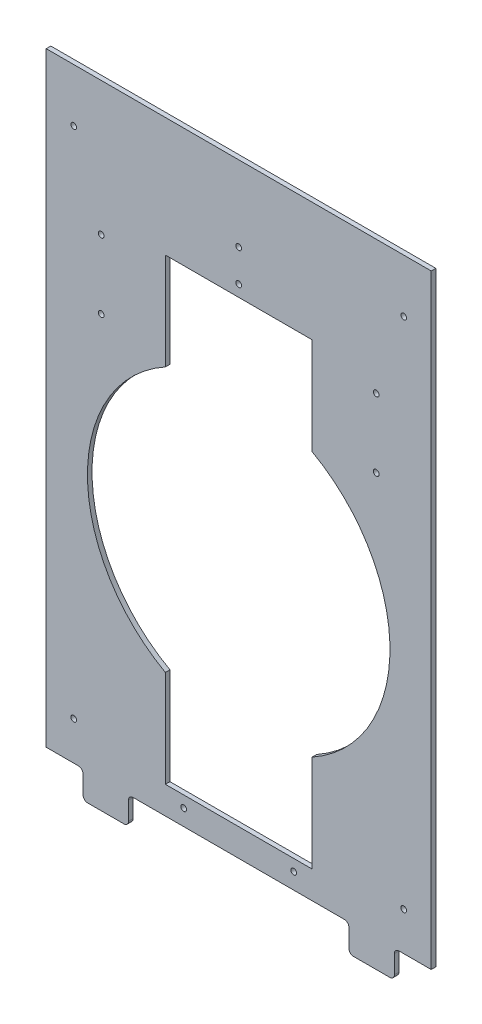
from build123d import *

# Parameters (mm, degrees)
SKETCH1_W                      = 533.4
SKETCH1_H                      = 2413
BOSS_EXTRUDE1_DEPTH            = 6.35
F_5_16_0_3125_DIAMETER_HOLE1_D = 7.9375
SKETCH6_W                      = 533.4
SKETCH6_H                      = 1546.86
CUT_EXTRUDE1_DEPTH             = 7.35
SKETCH7_W                      = 62.992
SKETCH7_H                      = 38.1
BOSS_EXTRUDE2_DEPTH            = 6.35
FILLET1_R                      = 6.35
SKETCH9_W                      = 533.4
SKETCH9_H                      = 27.94
CUT_EXTRUDE3_DEPTH             = 7.35
F_5_16_0_3125_DIAMETER_HOLE2_D = 7.9375


with BuildPart() as part:
    # Sketch1 → Boss-Extrude1 (new body)
    with BuildSketch(Plane.XY):
        with Locations((0, 1206.5)):
            Rectangle(SKETCH1_W, SKETCH1_H)
        with BuildLine():
            Line((-101.6, 797.56), (101.6, 797.56))
            Line((101.6, 797.56), (101.6, 663.332045059))
            ThreePointArc((101.6, 663.332045059), (209.55, 480.06), (101.6, 296.787954941))
            Line((101.6, 296.787954941), (101.6, 162.56))
            Line((101.6, 162.56), (-101.6, 162.56))
            Line((-101.6, 162.56), (-101.6, 296.787954941))
            ThreePointArc((-101.6, 296.787954941), (-209.55, 480.06), (-101.6, 663.332045059))
            Line((-101.6, 663.332045059), (-101.6, 797.56))
        make_face(mode=Mode.SUBTRACT)
        with BuildLine():
            Line((-101.6, 1508.76), (-101.6, 1374.532045059))
            ThreePointArc((-101.6, 1374.532045059), (-209.55, 1191.26), (-101.6, 1007.987954941))
            Line((-101.6, 1007.987954941), (-101.6, 873.76))
            Line((-101.6, 873.76), (101.6, 873.76))
            Line((101.6, 873.76), (101.6, 1007.987954941))
            ThreePointArc((101.6, 1007.987954941), (209.55, 1191.26), (101.6, 1374.532045059))
            Line((101.6, 1374.532045059), (101.6, 1508.76))
            Line((101.6, 1508.76), (-101.6, 1508.76))
        make_face(mode=Mode.SUBTRACT)
        with BuildLine():
            Line((-101.6, 2219.96), (-101.6, 2085.732045059))
            ThreePointArc((-101.6, 2085.732045059), (-209.55, 1902.46), (-101.6, 1719.187954941))
            Line((-101.6, 1719.187954941), (-101.6, 1584.96))
            Line((-101.6, 1584.96), (101.6, 1584.96))
            Line((101.6, 1584.96), (101.6, 1719.187954941))
            ThreePointArc((101.6, 1719.187954941), (209.55, 1902.46), (101.6, 2085.732045059))
            Line((101.6, 2085.732045059), (101.6, 2219.96))
            Line((101.6, 2219.96), (-101.6, 2219.96))
        make_face(mode=Mode.SUBTRACT)
    extrude(amount=BOSS_EXTRUDE1_DEPTH)

    # 5/16 (0.3125) Diameter Hole1 (through all)
    with Locations(Plane.XY.offset(6.35)):
        with Locations((-76.2, 146.685), (-76.2, 102.235), (-228.6, 177.8), (76.2, 102.235), (76.2, 146.685), (-76.2, 857.885), (-76.2, 813.435), (76.2, 813.435), (76.2, 857.885), (-76.2, 1569.085), (-76.2, 1524.635), (76.2, 1524.635), (76.2, 1569.085), (228.6, 177.8), (-228.6, 889), (228.6, 889), (-228.6, 1600.2), (228.6, 1600.2), (0, 2280.285), (0, 2235.835), (228.6, 2311.4), (-228.6, 2311.4)):
            Hole(F_5_16_0_3125_DIAMETER_HOLE1_D / 2)

    # Sketch6 → Cut-Extrude1 (cut, through all)
    with BuildSketch(Plane.XY.offset(6.35)):
        with Locations((0, 773.43)):
            Rectangle(SKETCH6_W, SKETCH6_H)
    extrude(amount=-CUT_EXTRUDE1_DEPTH, mode=Mode.SUBTRACT)

    # Sketch7 → Boss-Extrude2 (add)
    with BuildSketch(Plane.XY.offset(6.35)):
        with Locations((-184.15, 1527.81)):
            Rectangle(SKETCH7_W, SKETCH7_H)
        with Locations((184.15, 1527.81)):
            Rectangle(SKETCH7_W, SKETCH7_H)
    extrude(amount=-BOSS_EXTRUDE2_DEPTH)

    # Fillet1
    fillet1_edges = [part.edges().sort_by_distance(p)[0] for p in [
        (-152.654, 1508.76, 3.175),
        (-215.646, 1508.76, 3.175),
        (-215.646, 1546.86, 3.175),
        (-152.654, 1546.86, 3.175),
        (215.646, 1508.76, 3.175),
        (215.646, 1546.86, 3.175),
        (152.654, 1546.86, 3.175),
        (152.654, 1508.76, 3.175),
    ]]
    fillet(fillet1_edges, radius=FILLET1_R)

    # Sketch9 → Cut-Extrude3 (cut, through all)
    with BuildSketch(Plane.XY.offset(6.35)):
        with Locations((0, 2399.03)):
            Rectangle(SKETCH9_W, SKETCH9_H)
    extrude(amount=-CUT_EXTRUDE3_DEPTH, mode=Mode.SUBTRACT)

    # 5/16 (0.3125) Diameter Hole2 (through all)
    with Locations(Plane.XY.offset(6.35)):
        with Locations((-190.5, 2200.032045059), (-190.5, 2104.782045059), (190.5, 2200.032045059), (190.5, 2104.782045059)):
            Hole(F_5_16_0_3125_DIAMETER_HOLE2_D / 2)


solid = part.part
